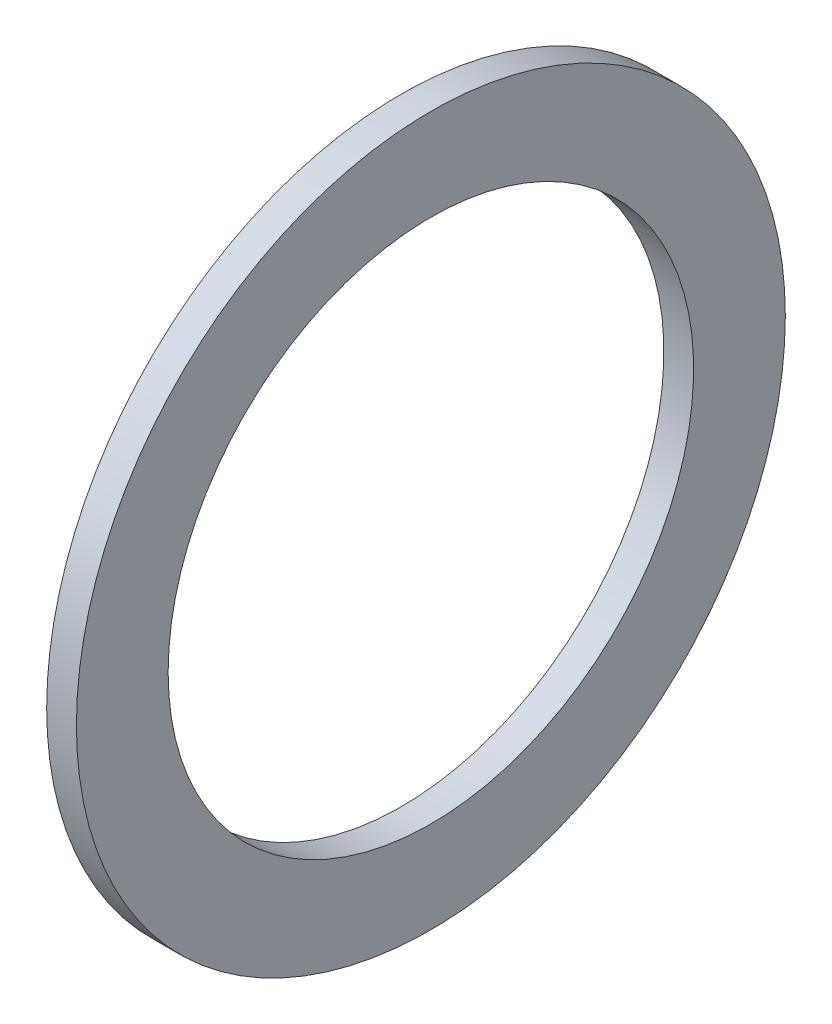
from build123d import *

# Parameters (mm, degrees)
SKETCH1_W = 1.524
SKETCH1_H = 4.699


with BuildPart() as part:
    # Sketch1 → Revolve1 (revolve)
    with BuildSketch(Plane.XY, mode=Mode.PRIVATE) as revolve1_sk:
        with Locations((0.762, -15.8115)):
            Rectangle(SKETCH1_W, SKETCH1_H)
    revolve(revolve1_sk.sketch.rotate(Axis((-43.716580756, 0, 0), (1, 0, 0)), 270), axis=Axis((-43.716580756, 0, 0), (1, 0, 0)))  # turned: the seam where the file's is


solid = part.part
